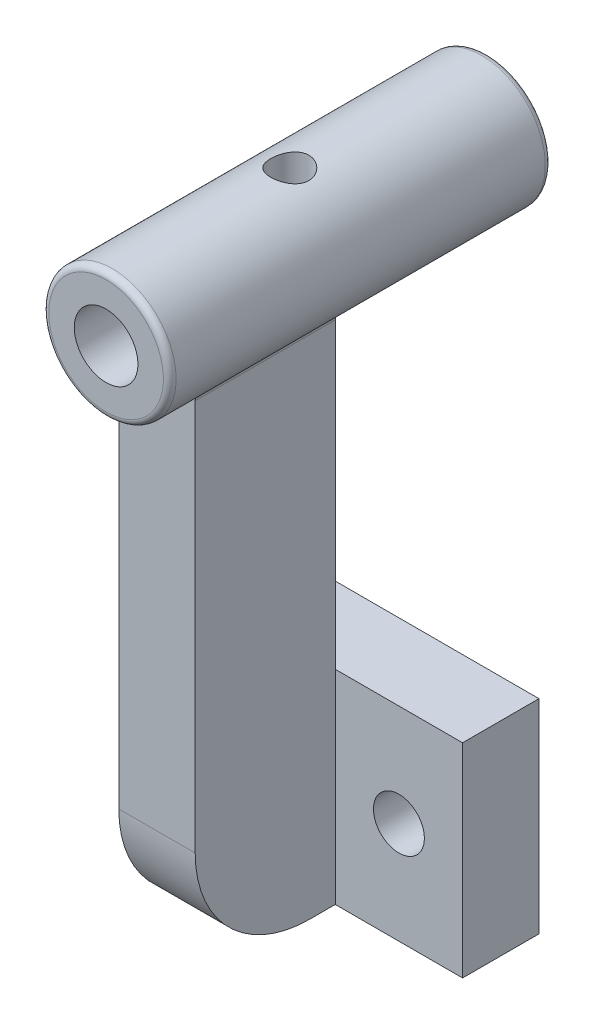
from build123d import *

# Parameters (mm, degrees)
SKETCH2_W                = 13
SKETCH2_H                = 16
SKETCH2_R                = 2
BOSS_EXTRUDE1_DEPTH      = 6
BOSS_EXTRUDE2_DEPTH      = 3
BOSS_EXTRUDE2_DEPTH_BACK = 3
SKETCH6_R                = 5
BOSS_EXTRUDE4_DEPTH      = 15
BOSS_EXTRUDE4_DEPTH_BACK = 15
SKETCH7_R                = 2.5
CUT_EXTRUDE2_DEPTH       = 31
FILLET3_R                = 0.5
FILLET4_R                = 0.5
SKETCH10_R               = 1.5
CUT_EXTRUDE3_DEPTH       = 4


with BuildPart() as part:
    # Sketch2 → Boss-Extrude1 (new body)
    with BuildSketch(Plane.XY):
        with Locations((-6.5, 8)):
            Rectangle(SKETCH2_W, SKETCH2_H)
        with Locations((-8, 8)):
            Circle(SKETCH2_R, mode=Mode.SUBTRACT)
        with Locations((6.5, 8)):
            Rectangle(SKETCH2_W, SKETCH2_H)
        with Locations((8, 8)):
            Circle(SKETCH2_R, mode=Mode.SUBTRACT)
    extrude(amount=BOSS_EXTRUDE1_DEPTH)

    # Sketch3 → Boss-Extrude2 (add, two sides)
    with BuildSketch(Plane(origin=(0, 0, 0), x_dir=(0, 0, -1), z_dir=(1, 0, 0))) as boss_extrude2_sk:
        with BuildLine():
            Line((-6, 0), (-8, 0))
            ThreePointArc((-8, 0), (-14.363961031, 2.636038969), (-17, 9))
            Line((-17, 9), (-17, 44))
            Line((-17, 44), (-6, 44))
            Line((-6, 44), (-6, 16))
            Line((-6, 16), (-6, 0))
        make_face()
    extrude(amount=BOSS_EXTRUDE2_DEPTH)
    extrude(boss_extrude2_sk.sketch, amount=-BOSS_EXTRUDE2_DEPTH_BACK)

    # Sketch6 → Boss-Extrude4 (add, two sides)
    with BuildSketch(Plane(origin=(0, 0, 6), x_dir=(-1, 0, 0), z_dir=(0, 0, -1))) as boss_extrude4_sk:
        with Locations((0, 44)):
            Circle(SKETCH6_R)
    extrude(amount=BOSS_EXTRUDE4_DEPTH)
    extrude(boss_extrude4_sk.sketch, amount=-BOSS_EXTRUDE4_DEPTH_BACK)

    # Sketch7 → Cut-Extrude2 (cut, through all)
    with BuildSketch(Plane(origin=(0, 0, -9), x_dir=(-1, 0, 0), z_dir=(0, 0, -1))):
        with Locations((0, 44)):
            Circle(SKETCH7_R)
    extrude(amount=-CUT_EXTRUDE2_DEPTH, mode=Mode.SUBTRACT)

    # Fillet3
    fillet3_edges = [part.edges().sort_by_distance(p)[0] for p in [
        (5, 44, 21),
        (5, 44, -9),
    ]]
    fillet(fillet3_edges, radius=FILLET3_R)

    # Fillet4
    fillet4_edges = [part.edges().sort_by_distance(p)[0] for p in [
        (3, 40, 11.5),
        (-3, 40, 11.5),
    ]]
    fillet(fillet4_edges, radius=FILLET4_R)

    # Sketch10 → Cut-Extrude3 (cut)
    with BuildSketch(Plane.ZX.offset(49)):
        with Locations((6.569879023, 0)):
            Circle(SKETCH10_R)
    extrude(amount=-CUT_EXTRUDE3_DEPTH, mode=Mode.SUBTRACT)


solid = part.part
